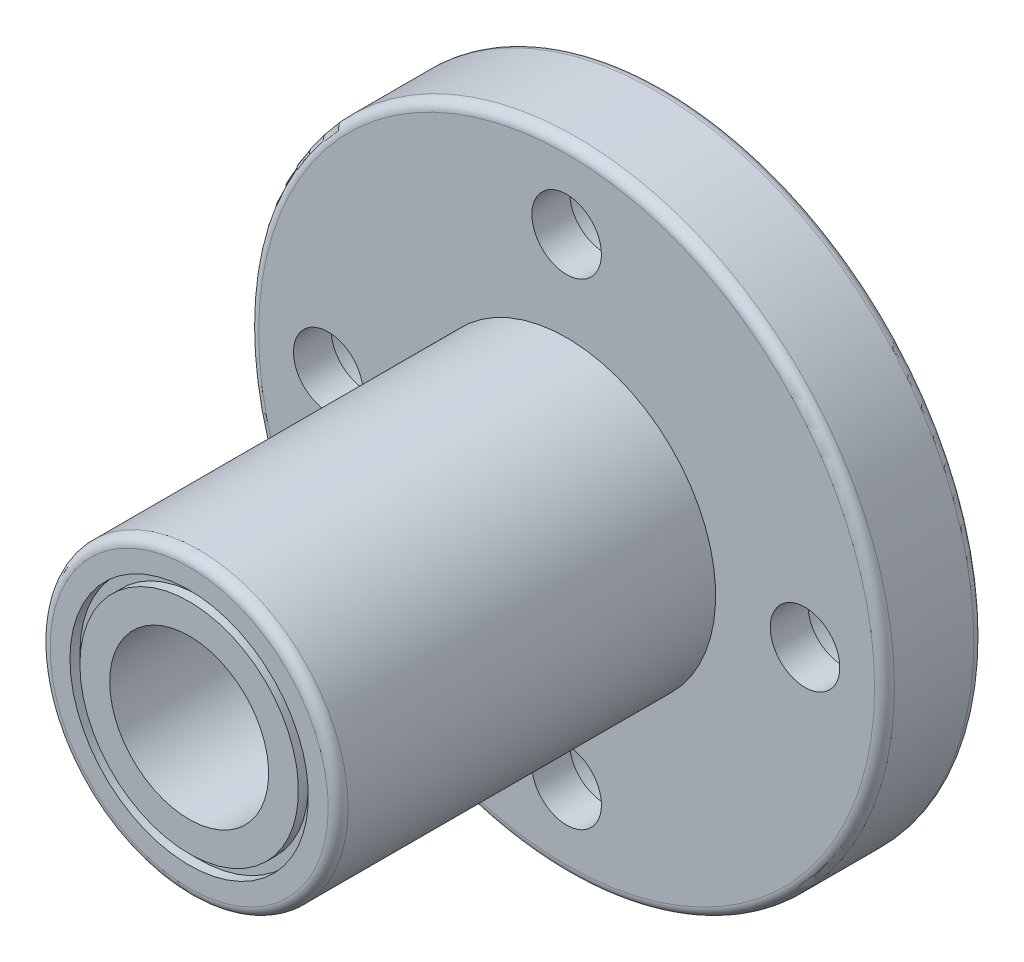
from build123d import *

# Parameters (mm, degrees)
PADR_OCIRCULAR1_COUNT = 4
FILETE1_R             = 0.5


with BuildPart() as part:
    # Esboço1 → Revolução1 (revolve)
    with BuildSketch(Plane(origin=(0, 0, 0), x_dir=(0, 0, -1), z_dir=(1, 0, 0)), mode=Mode.PRIVATE) as revolu_o1_sk:
        Polygon((0, 4), (0, 5.5), (-0.5, 5.5), (-0.5, 6), (0, 6), (0, 7), (-0.5, 7), (-0.5, 7.5), (0, 7.5), (0, 16), (-5, 16), (-5, 7.5), (-24, 7.5), (-24, 6), (-23.5, 6), (-23.5, 5.5), (-24, 5.5), (-24, 4), align=None)
    revolve(revolu_o1_sk.sketch.rotate(Axis((0, 0, 0), (0, 0, 1)), 90), axis=Axis((0, 0, 0), (0, 0, 1)))  # turned: the seam where the file's is

    # Esboço5 → Corte-Revolução1 (revolve, cut)
    with BuildSketch(Plane(origin=(0, 0, 0), x_dir=(0, 0, -1), z_dir=(1, 0, 0)), mode=Mode.PRIVATE) as corte_revolu_o1_sk:
        Polygon((0, 15), (-3.1, 15), (-3.1, 13.75), (-5, 13.75), (-5, 12), (0, 12), align=None)
    corte_revolu_o1 = revolve(corte_revolu_o1_sk.sketch.rotate(Axis((0, 12, 0), (0, 0, -1)), 180), axis=Axis((0, 12, 0), (0, 0, -1)), mode=Mode.SUBTRACT)  # turned: the seam where the file's is

    # PadrãoCircular1: Corte-Revolução1 ×4 about axis
    padr_ocircular1_axis = Axis((0, 0, 0), (0, 0, 1))
    for i in range(1, PADR_OCIRCULAR1_COUNT):
        add(corte_revolu_o1.rotate(padr_ocircular1_axis, i * 360 / PADR_OCIRCULAR1_COUNT), mode=Mode.SUBTRACT)

    # Filete1
    filete1_edges = [part.edges().sort_by_distance(p)[0] for p in [
        (7.5, 0, 24),
        (16, 0, 5),
        (16, 0, 0),
    ]]
    fillet(filete1_edges, radius=FILETE1_R)


solid = part.part
